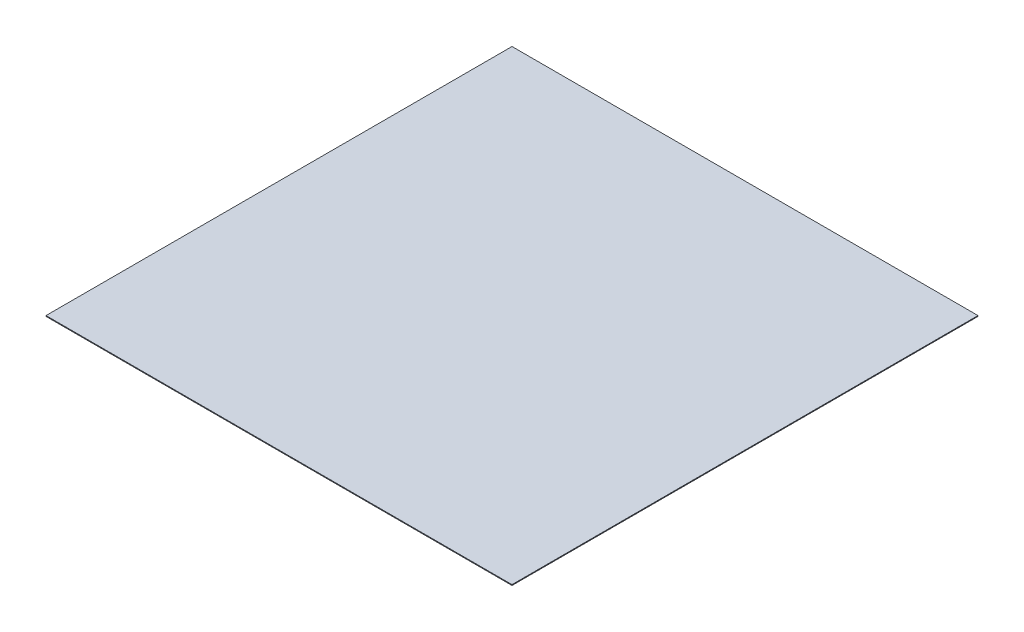
from build123d import *

# Parameters (mm, degrees)
SKETCH1_W           = 1524
SKETCH1_H           = 1524
BOSS_EXTRUDE1_DEPTH = 2.54


with BuildPart() as part:
    # Sketch1 → Boss-Extrude1 (new body)
    with BuildSketch(Plane(origin=(0, 0, 0), x_dir=(1, 0, 0), z_dir=(0, 1, 0))):
        with Locations((762, 762)):
            Rectangle(SKETCH1_W, SKETCH1_H)
    extrude(amount=BOSS_EXTRUDE1_DEPTH)


solid = part.part
